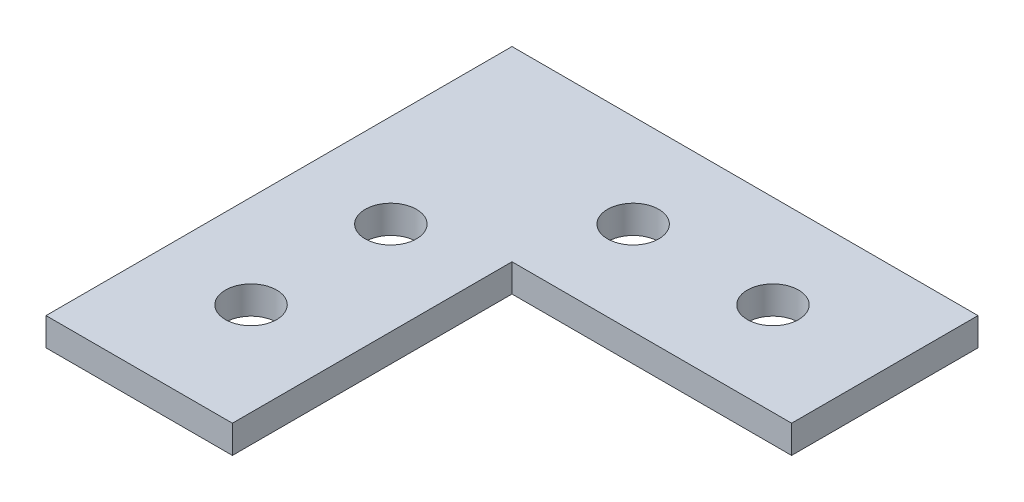
from build123d import *

# Parameters (mm, degrees)
SKETCH1_W           = 20
SKETCH1_H           = 50
SKETCH1_W_2         = 30
SKETCH1_H_2         = 20
BOSS_EXTRUDE1_DEPTH = 3
SKETCH3_R           = 2.75
CUT_EXTRUDE1_DEPTH  = 3


with BuildPart() as part:
    # Sketch1 → Boss-Extrude1 (new body)
    with BuildSketch(Plane(origin=(0, 0, 0), x_dir=(1, 0, 0), z_dir=(0, 1, 0))):
        with Locations((10, -25)):
            Rectangle(SKETCH1_W, SKETCH1_H)
        with Locations((35, -10)):
            Rectangle(SKETCH1_W_2, SKETCH1_H_2)
    extrude(amount=BOSS_EXTRUDE1_DEPTH)

    # Sketch3 → Cut-Extrude1 (cut)
    with BuildSketch(Plane(origin=(0, 3, 0), x_dir=(1, 0, 0), z_dir=(0, 1, 0))):
        with Locations((10, -38)):
            Circle(SKETCH3_R)
        with Locations((10, -23)):
            Circle(SKETCH3_R)
        with Locations((38, -10)):
            Circle(SKETCH3_R)
        with Locations((23, -10)):
            Circle(SKETCH3_R)
    extrude(amount=-CUT_EXTRUDE1_DEPTH, mode=Mode.SUBTRACT)


solid = part.part
